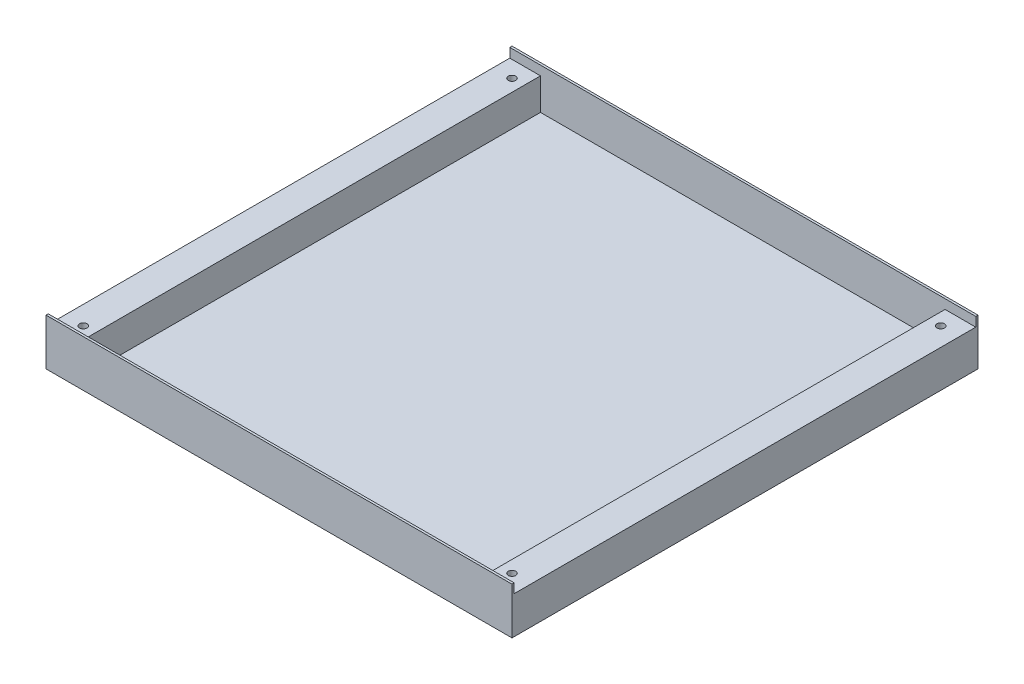
from build123d import *

# Parameters (mm, degrees)
ESBO_O1_W                = 250
ESBO_O1_H                = 250
ESBO_O1_R                = 2
RESSALTO_EXTRUS_O1_DEPTH = 3
ESBO_O2_W                = 16.471941672
ESBO_O2_H                = 247.6
ESBO_O2_R                = 2
RESSALTO_EXTRUS_O2_DEPTH = 17
ESBO_O2_5_W              = 250
ESBO_O2_5_H              = 1.2
RESSALTO_EXTRUS_O3_DEPTH = 22


with BuildPart() as part:
    # Esboço1 → Ressalto-extrusão1 (new body)
    with BuildSketch(Plane(origin=(0, 0, 0), x_dir=(1, 0, 0), z_dir=(0, 1, 0))):
        Rectangle(ESBO_O1_W, ESBO_O1_H)
        with Locations((-115, 115)):
            Circle(ESBO_O1_R, mode=Mode.SUBTRACT)
        with Locations((115, 115)):
            Circle(ESBO_O1_R, mode=Mode.SUBTRACT)
        with Locations((-115, -115)):
            Circle(ESBO_O1_R, mode=Mode.SUBTRACT)
        with Locations((115, -115)):
            Circle(ESBO_O1_R, mode=Mode.SUBTRACT)
    extrude(amount=RESSALTO_EXTRUS_O1_DEPTH)

    # Esboço2 → Ressalto-extrusão2 (add)
    # profile 1 of 2: a face of its own
    with BuildSketch(Plane(origin=(0, 3, 0), x_dir=(1, 0, 0), z_dir=(0, 1, 0))):
        with Locations((-116.764029164, 0)):
            Rectangle(ESBO_O2_W, ESBO_O2_H)
        with Locations((-115, -115)):
            Circle(ESBO_O2_R, mode=Mode.SUBTRACT)
        with Locations((-115, 115)):
            Circle(ESBO_O2_R, mode=Mode.SUBTRACT)
    # profile 2 of 2: a face of its own
    with BuildSketch(Plane(origin=(0, 3, 0), x_dir=(1, 0, 0), z_dir=(0, 1, 0))):
        with Locations((116.764029164, 0)):
            Rectangle(ESBO_O2_W, ESBO_O2_H)
        with Locations((115, -115)):
            Circle(ESBO_O2_R, mode=Mode.SUBTRACT)
        with Locations((115, 115)):
            Circle(ESBO_O2_R, mode=Mode.SUBTRACT)
    extrude(amount=RESSALTO_EXTRUS_O2_DEPTH)

    # Esboço2<5> → Ressalto-extrusão3 (add)
    with BuildSketch(Plane(origin=(0, 3, 0), x_dir=(1, 0, 0), z_dir=(0, 1, 0))):
        with Locations((0, 124.4)):
            Rectangle(ESBO_O2_5_W, ESBO_O2_5_H)
        with Locations((0, -124.4)):
            Rectangle(ESBO_O2_5_W, ESBO_O2_5_H)
    extrude(amount=RESSALTO_EXTRUS_O3_DEPTH)


solid = part.part
